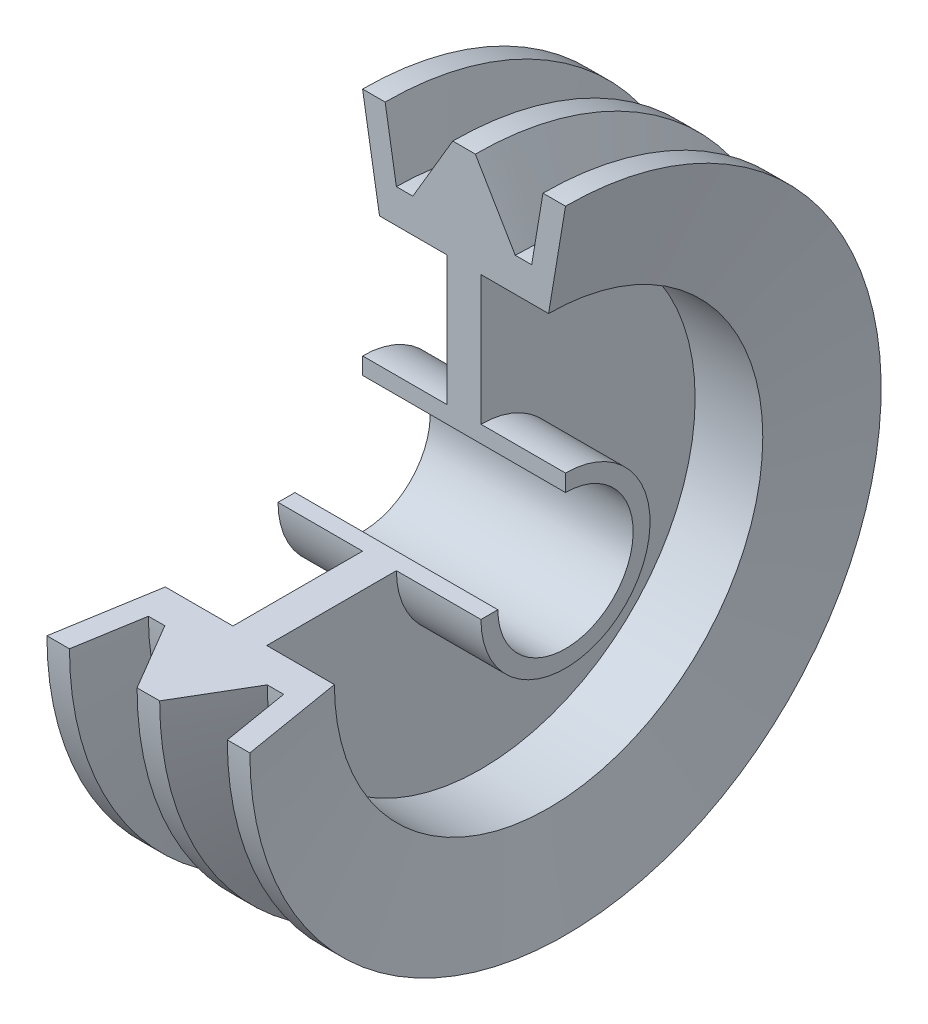
from build123d import *

# Parameters (mm, degrees)
REVOLVE5_ANGLE = 270


with BuildPart() as part:
    # Sketch1 → Revolve5 (revolve)
    with BuildSketch(Plane.XY):
        Polygon((-35.442504871, -11.710433312), (-35.442504871, -19.210433312), (54.557495129, -19.210433312), (54.557495129, -11.710433312), (17.057495129, -11.710433312), (17.057495129, 45.789566688), (47.057495129, 45.789566688), (54.557495129, 90.789566688), (44.557495129, 90.789566688), (39.557495129, 60.789566688), (32.265242588, 60.789566688), (14.567304664, 90.789573408), (4.557495129, 90.80620168), (-13.15025233, 60.789566688), (-20.442504871, 60.789566688), (-25.442504871, 90.789566688), (-35.442504871, 90.789566688), (-27.942504871, 45.789566688), (2.057495129, 45.789566688), (2.057495129, -11.710433312), align=None)
    revolve(axis=Axis((-35.442504871, -49.210433312, 0), (-1, 0, 0)), revolution_arc=REVOLVE5_ANGLE)


solid = part.part
